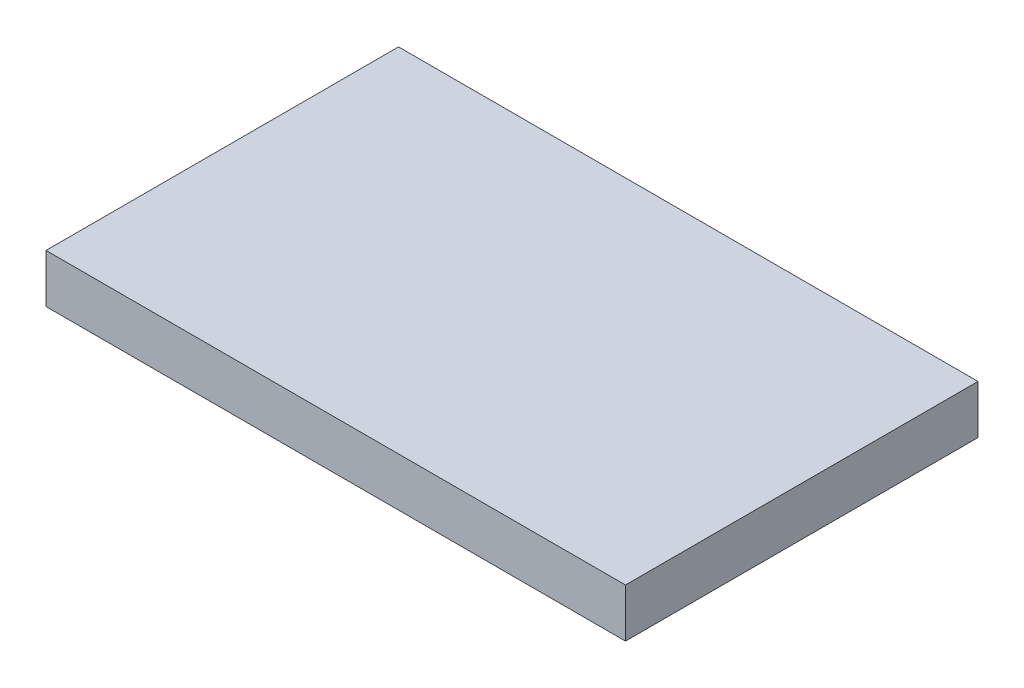
from build123d import *

# Parameters (mm, degrees)
SKETCH1_W           = 143
SKETCH1_H           = 87
BOSS_EXTRUDE1_DEPTH = 12


with BuildPart() as part:
    # Sketch1 → Boss-Extrude1 (new body)
    with BuildSketch(Plane(origin=(0, 0, 0), x_dir=(1, 0, 0), z_dir=(0, 1, 0))):
        with Locations((53.120801034, 7.898901809)):
            Rectangle(SKETCH1_W, SKETCH1_H)
    extrude(amount=BOSS_EXTRUDE1_DEPTH)


solid = part.part
